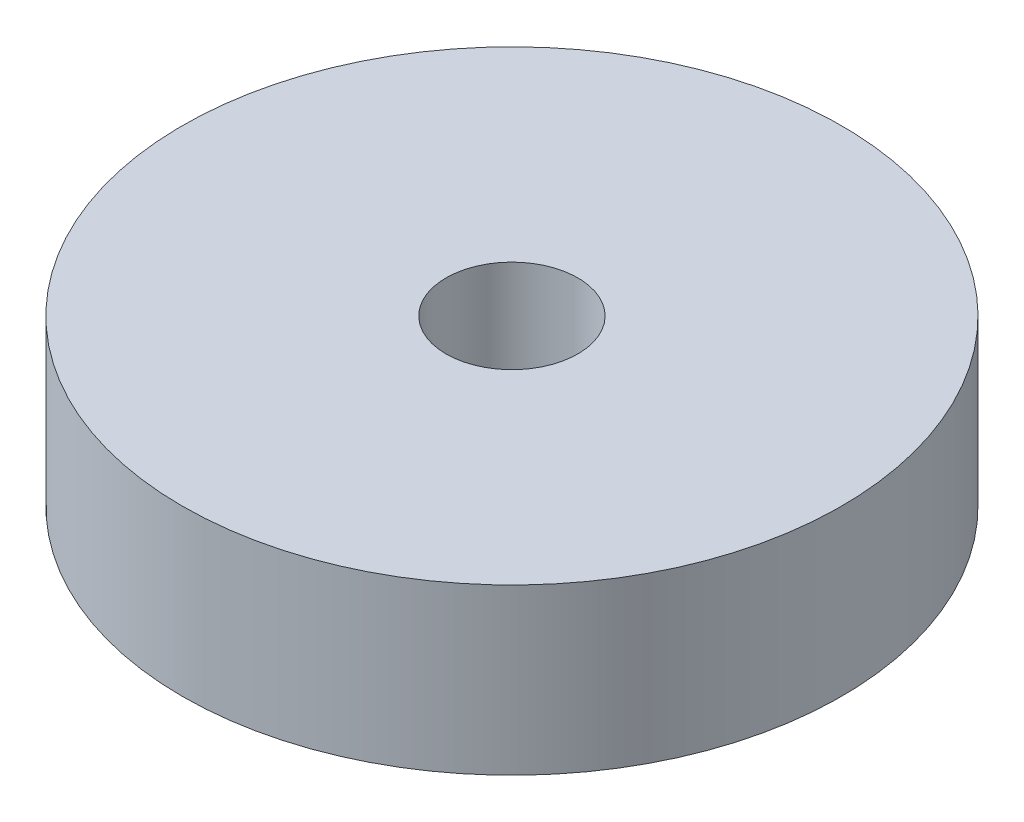
from build123d import *

# Parameters (mm, degrees)
SKETCH1_R           = 20
SKETCH1_R_2         = 4
BOSS_EXTRUDE1_DEPTH = 10
CUT_EXTRUDE1_DEPTH  = 7
SKETCH4_R           = 2.125
CUT_EXTRUDE2_DEPTH  = 3.000006


with BuildPart() as part:
    # Sketch1 → Boss-Extrude1 (new body)
    with BuildSketch(Plane(origin=(0, 0, 0), x_dir=(1, 0, 0), z_dir=(0, 1, 0))):
        Circle(SKETCH1_R)
        Circle(SKETCH1_R_2, mode=Mode.SUBTRACT)
    extrude(amount=BOSS_EXTRUDE1_DEPTH)

    # Sketch3 → Cut-Extrude1 (cut)
    with BuildSketch(Plane(origin=(0, 0, 0), x_dir=(1, 0, 0), z_dir=(0, 1, 0))):
        with BuildLine():
            Line((-12.000006, 3.320491078), (-12.000006, -3.320491078))
            ThreePointArc((-12.000006, -3.320491078), (-15, -4.475), (-17.999994, -3.320491078))
            Line((-17.999994, -3.320491078), (-17.999994, 3.320491078))
            ThreePointArc((-17.999994, 3.320491078), (-15, 4.475), (-12.000006, 3.320491078))
        make_face()
    extrude(amount=CUT_EXTRUDE1_DEPTH, mode=Mode.SUBTRACT)

    # Sketch4 → Cut-Extrude2 (cut, through all)
    with BuildSketch(Plane(origin=(-17.999994, 0, 0), x_dir=(0, 0, -1), z_dir=(1, 0, 0))):
        with Locations((0, 3)):
            Circle(SKETCH4_R)
    extrude(amount=-CUT_EXTRUDE2_DEPTH, mode=Mode.SUBTRACT)


solid = part.part
